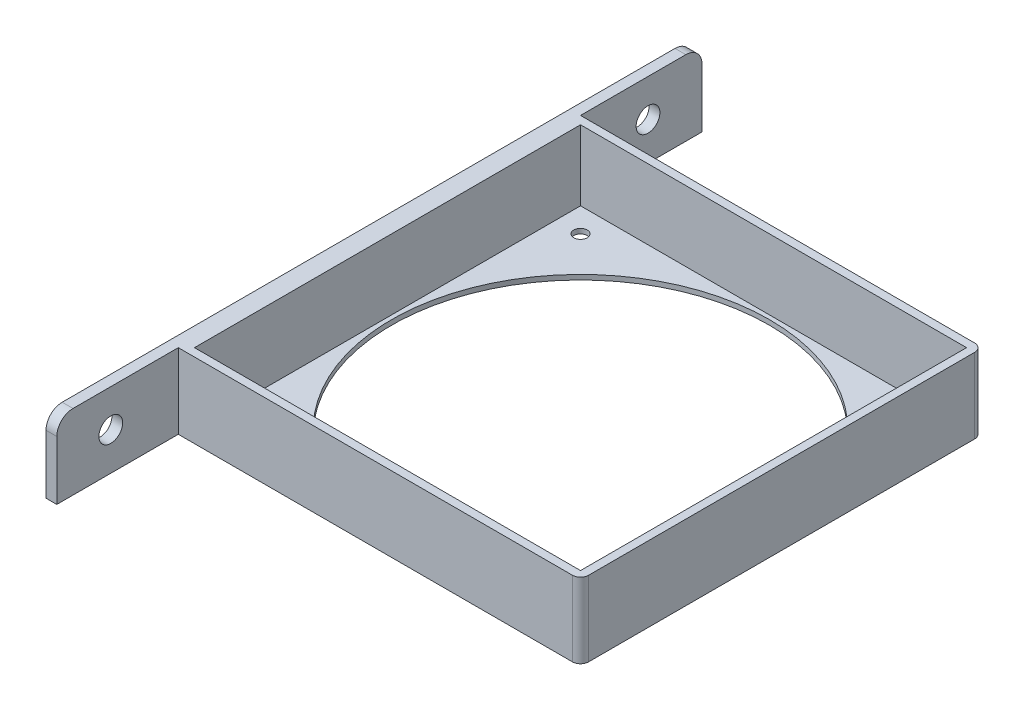
from build123d import *

# Parameters (mm, degrees)
SKETCH1_W           = 143
SKETCH1_H           = 143
BOSS_EXTRUDE1_DEPTH = 26
SKETCH2_R           = 70
SKETCH2_R_2         = 2.5
BOSS_EXTRUDE2_DEPTH = 1.8
SKETCH3_R           = 4.4
BOSS_EXTRUDE4_DEPTH = 4


with BuildPart() as part:
    # Sketch1 → Boss-Extrude1 (new body)
    with BuildSketch(Plane(origin=(0, 0, 0), x_dir=(1, 0, 0), z_dir=(0, 1, 0))):
        with BuildLine():
            Line((74.5, 71.5), (74.5, -71.5))
            ThreePointArc((74.5, -71.5), (73.621320344, -73.621320344), (71.5, -74.5))
            Line((71.5, -74.5), (-74.5, -74.5))
            Line((-74.5, -74.5), (-74.5, 74.5))
            Line((-74.5, 74.5), (71.5, 74.5))
            ThreePointArc((71.5, 74.5), (73.621320344, 73.621320344), (74.5, 71.5))
        make_face()
        Rectangle(SKETCH1_W, SKETCH1_H, mode=Mode.SUBTRACT)
    extrude(amount=BOSS_EXTRUDE1_DEPTH)

    # Sketch2 → Boss-Extrude2 (add)
    with BuildSketch(Plane.XZ):
        with BuildLine():
            Line((74.5, -71.5), (74.5, 71.5))
            ThreePointArc((74.5, 71.5), (73.621320344, 73.621320344), (71.5, 74.5))
            Line((71.5, 74.5), (-74.5, 74.5))
            Line((-74.5, 74.5), (-74.5, -74.5))
            Line((-74.5, -74.5), (71.5, -74.5))
            ThreePointArc((71.5, -74.5), (73.621320344, -73.621320344), (74.5, -71.5))
        make_face()
        with Locations(Location((0, 0, 0), (0, 0, 270))):
            Circle(SKETCH2_R, mode=Mode.SUBTRACT)
        with Locations(Location((-62.5, 62.5, 0), (0, 0, 270))):
            Circle(SKETCH2_R_2, mode=Mode.SUBTRACT)
        with Locations(Location((62.5, 62.5, 0), (0, 0, 270))):
            Circle(SKETCH2_R_2, mode=Mode.SUBTRACT)
        with Locations(Location((62.5, -62.5, 0), (0, 0, 270))):
            Circle(SKETCH2_R_2, mode=Mode.SUBTRACT)
        with Locations(Location((-62.5, -62.5, 0), (0, 0, 270))):
            Circle(SKETCH2_R_2, mode=Mode.SUBTRACT)
    extrude(amount=BOSS_EXTRUDE2_DEPTH)

    # Sketch3 → Boss-Extrude4 (add)
    with BuildSketch(Plane.ZY.offset(74.5)):
        with BuildLine():
            Line((-113.5, 26), (113.5, 26))
            ThreePointArc((113.5, 26), (117.742640687, 24.242640687), (119.5, 20))
            Line((119.5, 20), (119.5, -1.8))
            Line((119.5, -1.8), (-119.5, -1.8))
            Line((-119.5, -1.8), (-119.5, 20))
            ThreePointArc((-119.5, 20), (-117.742640687, 24.242640687), (-113.5, 26))
        make_face()
        with Locations((-99.5, 12.2)):
            Circle(SKETCH3_R, mode=Mode.SUBTRACT)
        with Locations((99.5, 12.2)):
            Circle(SKETCH3_R, mode=Mode.SUBTRACT)
    extrude(amount=BOSS_EXTRUDE4_DEPTH)


solid = part.part
